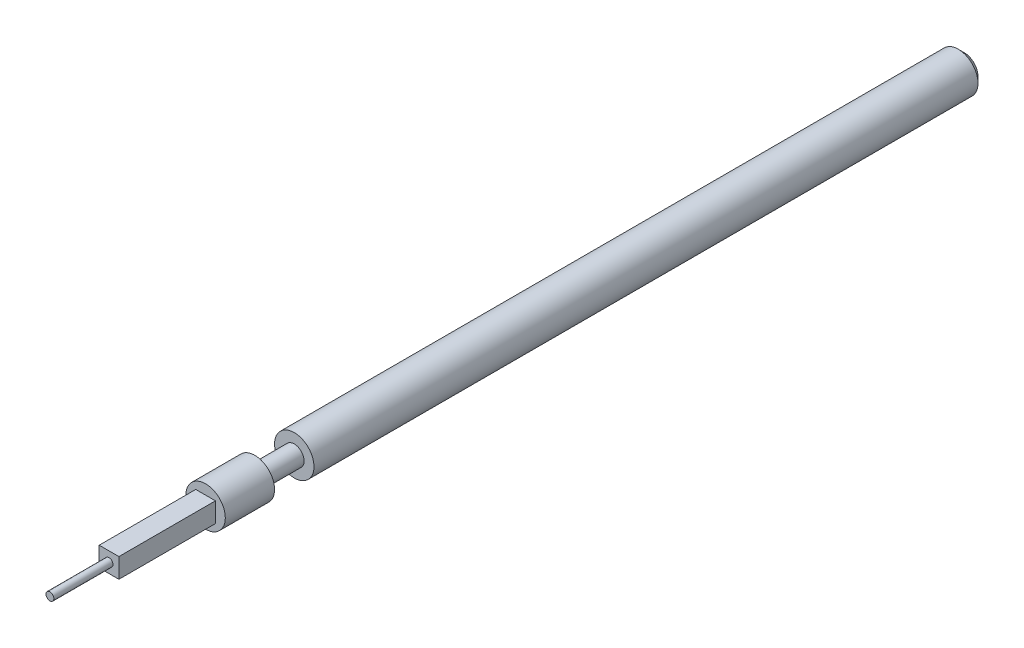
from build123d import *

# Parameters (mm, degrees)
CROQUIS1_R              = 0.5
SALIENTE_EXTRUIR1_DEPTH = 17
CHAFL_N1_SIZE           = 0.15
CROQUIS6_R              = 0.25
SALIENTE_EXTRUIR2_DEPTH = 1
CROQUIS7_R              = 0.5
SALIENTE_EXTRUIR3_DEPTH = 1.25
CROQUIS8_W              = 0.5
CROQUIS8_H              = 0.5
SALIENTE_EXTRUIR4_DEPTH = 2.45
CROQUIS9_R              = 0.1
SALIENTE_EXTRUIR5_DEPTH = 1.5


with BuildPart() as part:
    # Croquis1 → Saliente-Extruir1 (new body)
    with BuildSketch(Plane.XY):
        Circle(CROQUIS1_R)
    extrude(amount=SALIENTE_EXTRUIR1_DEPTH)

    # Chaflán1
    chafl_n1_edges = [part.edges().sort_by_distance(p)[0] for p in [
        (-0.5, 0, 0),
    ]]
    chamfer(chafl_n1_edges, length=CHAFL_N1_SIZE)

    # Croquis6 → Saliente-Extruir2 (add)
    with BuildSketch(Plane.XY.offset(17)):
        Circle(CROQUIS6_R)
    extrude(amount=SALIENTE_EXTRUIR2_DEPTH)

    # Croquis7 → Saliente-Extruir3 (add)
    with BuildSketch(Plane.XY.offset(18)):
        Circle(CROQUIS7_R)
    extrude(amount=SALIENTE_EXTRUIR3_DEPTH)

    # Croquis8 → Saliente-Extruir4 (add)
    with BuildSketch(Plane.XY.offset(19.25)):
        Rectangle(CROQUIS8_W, CROQUIS8_H)
    extrude(amount=SALIENTE_EXTRUIR4_DEPTH)

    # Croquis9 → Saliente-Extruir5 (add)
    with BuildSketch(Plane.XY.offset(21.7)):
        Circle(CROQUIS9_R)
    extrude(amount=SALIENTE_EXTRUIR5_DEPTH)


solid = part.part
